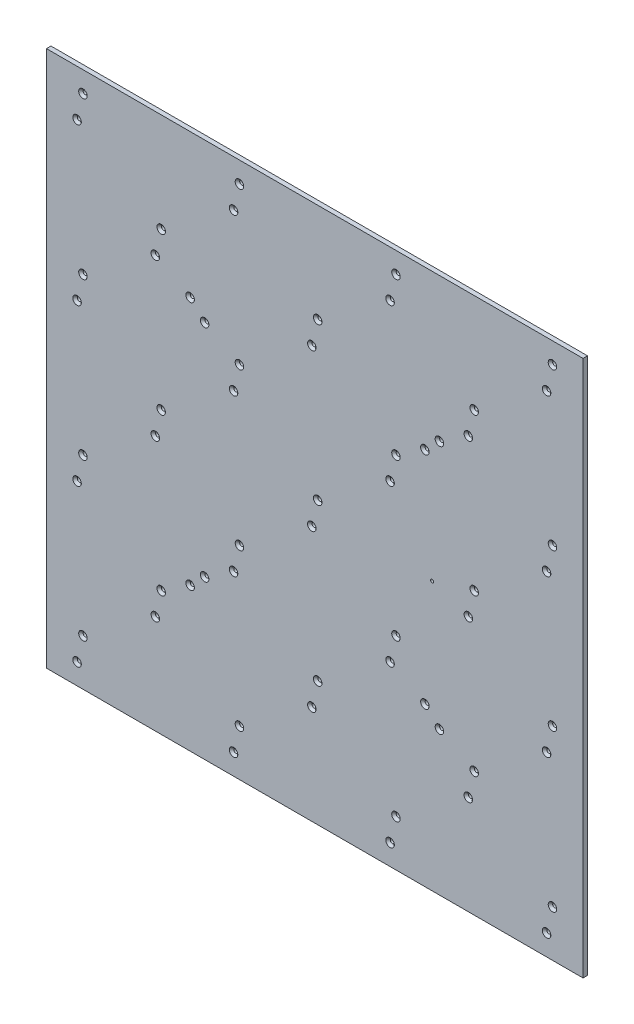
from build123d import *

# Parameters (mm, degrees)
BOSS_EXTRUDE1_START = 3
SKETCH1_W           = 1200
SKETCH1_H           = 1200
BOSS_EXTRUDE1_DEPTH = 10
SKETCH2_R           = 4.5
CUT_EXTRUDE1_DEPTH  = 11
CHAMFER1_SIZE       = 5
CUT_EXTRUDE2_REACH  = 12
SKETCH3_R           = 3.4


with BuildPart() as part:
    # Sketch1 → Boss-Extrude1 (new body)
    with BuildSketch(Plane.XY.offset(BOSS_EXTRUDE1_START)):
        Rectangle(SKETCH1_W, SKETCH1_H)
    extrude(amount=-BOSS_EXTRUDE1_DEPTH)

    # Sketch2 → Cut-Extrude1 (cut, through all)
    with BuildSketch(Plane(origin=(0, 0, -7), x_dir=(-1, 0, 0), z_dir=(0, 0, -1))):
        with Locations((-278.749982464, 278.776929471)):
            Circle(SKETCH2_R)
        with Locations((-246.223070529, 246.250017536)):
            Circle(SKETCH2_R)
        with Locations((246.250017536, 246.223070529)):
            Circle(SKETCH2_R)
        with Locations((278.776929471, 278.749982464)):
            Circle(SKETCH2_R)
        with Locations((246.223070529, -246.250017536)):
            Circle(SKETCH2_R)
        with Locations((278.749982464, -278.776929471)):
            Circle(SKETCH2_R)
        with Locations((-246.250017536, -246.223070529)):
            Circle(SKETCH2_R)
        with Locations((-278.776929471, -278.749982464)):
            Circle(SKETCH2_R)
        with Locations((-531.581664893, 553.513118765)):
            Circle(SKETCH2_R)
        with Locations((-518.429478763, 496.520312201)):
            Circle(SKETCH2_R)
        with Locations((-531.581664893, 203.509404213)):
            Circle(SKETCH2_R)
        with Locations((-518.429478763, 146.516597649)):
            Circle(SKETCH2_R)
        with Locations((-343.427621487, 321.518454925)):
            Circle(SKETCH2_R)
        with Locations((-356.579807617, 378.511261489)):
            Circle(SKETCH2_R)
        with Locations((-181.577950341, 553.513118765)):
            Circle(SKETCH2_R)
        with Locations((-168.425764211, 496.520312201)):
            Circle(SKETCH2_R)
        with Locations((168.425764211, 553.513118765)):
            Circle(SKETCH2_R)
        with Locations((181.577950341, 496.520312201)):
            Circle(SKETCH2_R)
        with Locations((-6.576093065, 378.511261489)):
            Circle(SKETCH2_R)
        with Locations((6.576093065, 321.518454925)):
            Circle(SKETCH2_R)
        with Locations((-181.577950341, 203.509404213)):
            Circle(SKETCH2_R)
        with Locations((-168.425764211, 146.516597649)):
            Circle(SKETCH2_R)
        with Locations((-356.579807617, 28.507546937)):
            Circle(SKETCH2_R)
        with Locations((-343.427621487, -28.485259627)):
            Circle(SKETCH2_R)
        with Locations((-518.429478763, -203.487116903)):
            Circle(SKETCH2_R)
        with Locations((-531.581664893, -146.494310339)):
            Circle(SKETCH2_R)
        with Locations((-531.581664893, -496.498024891)):
            Circle(SKETCH2_R)
        with Locations((-518.429478763, -553.490831454)):
            Circle(SKETCH2_R)
        with Locations((-356.579807617, -321.496167615)):
            Circle(SKETCH2_R)
        with Locations((-343.427621487, -378.488974178)):
            Circle(SKETCH2_R)
        with Locations((-181.577950341, -146.494310339)):
            Circle(SKETCH2_R)
        with Locations((-168.425764211, -203.487116903)):
            Circle(SKETCH2_R)
        with Locations((-6.576093065, 28.507546937)):
            Circle(SKETCH2_R)
        with Locations((6.576093065, -28.485259627)):
            Circle(SKETCH2_R)
        with Locations((168.425764211, 203.509404213)):
            Circle(SKETCH2_R)
        with Locations((181.577950341, 146.516597649)):
            Circle(SKETCH2_R)
        with Locations((343.427621487, 378.511261489)):
            Circle(SKETCH2_R)
        with Locations((356.579807617, 321.518454925)):
            Circle(SKETCH2_R)
        with Locations((518.429478763, 553.513118765)):
            Circle(SKETCH2_R)
        with Locations((531.581664893, 496.520312201)):
            Circle(SKETCH2_R)
        with Locations((-181.577950341, -496.498024891)):
            Circle(SKETCH2_R)
        with Locations((-168.425764211, -553.490831454)):
            Circle(SKETCH2_R)
        with Locations((-6.576093065, -321.496167615)):
            Circle(SKETCH2_R)
        with Locations((6.576093065, -378.488974178)):
            Circle(SKETCH2_R)
        with Locations((168.425764211, -146.494310339)):
            Circle(SKETCH2_R)
        with Locations((181.577950341, -203.487116903)):
            Circle(SKETCH2_R)
        with Locations((343.427621487, 28.507546937)):
            Circle(SKETCH2_R)
        with Locations((356.579807617, -28.485259627)):
            Circle(SKETCH2_R)
        with Locations((518.429478763, 203.509404213)):
            Circle(SKETCH2_R)
        with Locations((531.581664893, 146.516597649)):
            Circle(SKETCH2_R)
        with Locations((168.425764211, -496.498024891)):
            Circle(SKETCH2_R)
        with Locations((181.577950341, -553.490831454)):
            Circle(SKETCH2_R)
        with Locations((343.427621487, -321.496167615)):
            Circle(SKETCH2_R)
        with Locations((356.579807617, -378.488974178)):
            Circle(SKETCH2_R)
        with Locations((531.581664893, -203.487116903)):
            Circle(SKETCH2_R)
        with Locations((518.429478763, -146.494310339)):
            Circle(SKETCH2_R)
        with Locations((518.429478763, -496.498024891)):
            Circle(SKETCH2_R)
        with Locations((531.581664893, -553.490831454)):
            Circle(SKETCH2_R)
    extrude(amount=-CUT_EXTRUDE1_DEPTH, mode=Mode.SUBTRACT)

    # Chamfer1
    chamfer1_edges = [part.edges().sort_by_distance(p)[0] for p in [
        (522.929478763, -553.490831454, 3),
        (361.079807617, -321.496167615, 3),
        (347.927621487, -378.488974178, 3),
        (186.077950341, -146.494310339, 3),
        (172.925764211, -203.487116903, 3),
        (11.076093065, 28.507546937, 3),
        (536.081664893, 553.513118765, 3),
        (283.276929471, -278.749982464, 3),
        (250.750017536, -246.223070529, 3),
        (-274.249982464, -278.776929471, 3),
        (283.249982464, 278.776929471, 3),
        (-241.750017536, 246.223070529, 3),
        (-274.276929471, 278.749982464, 3),
        (-241.723070529, -246.250017536, 3),
        (-163.925764211, 553.513118765, 3),
        (172.925764211, 496.520312201, 3),
        (186.077950341, 553.513118765, 3),
        (361.079807617, 378.511261489, 3),
        (522.929478763, 496.520312201, 3),
        (536.081664893, 203.509404213, 3),
        (522.929478763, 146.516597649, 3),
        (347.927621487, 321.518454925, 3),
        (-352.079807617, -378.488974178, 3),
        (-527.081664893, -203.487116903, 3),
        (-513.929478763, -146.494310339, 3),
        (-513.929478763, -496.498024891, 3),
        (-527.081664893, 146.516597649, 3),
        (-163.925764211, -496.498024891, 3),
        (-177.077950341, -553.490831454, 3),
        (-338.927621487, -321.496167615, 3),
        (-527.081664893, -553.490831454, 3),
        (-352.079807617, 321.518454925, 3),
        (-513.929478763, 553.513118765, 3),
        (-527.081664893, 496.520312201, 3),
        (186.077950341, -496.498024891, 3),
        (-338.927621487, 378.511261489, 3),
        (-177.077950341, 146.516597649, 3),
        (-163.925764211, 203.509404213, 3),
        (-2.076093065, -28.485259627, 3),
        (172.925764211, -553.490831454, 3),
        (11.076093065, -321.496167615, 3),
        (-2.076093065, -378.488974178, 3),
        (-163.925764211, -146.494310339, 3),
        (-177.077950341, -203.487116903, 3),
        (-338.927621487, 28.507546937, 3),
        (-352.079807617, -28.485259627, 3),
        (-513.929478763, 203.509404213, 3),
        (250.723070529, 246.250017536, 3),
        (-177.077950341, 496.520312201, 3),
        (11.076093065, 378.511261489, 3),
        (-2.076093065, 321.518454925, 3),
        (186.077950341, 203.509404213, 3),
        (172.925764211, 146.516597649, 3),
        (361.079807617, 28.507546937, 3),
        (347.927621487, -28.485259627, 3),
        (522.929478763, -203.487116903, 3),
        (536.081664893, -146.494310339, 3),
        (536.081664893, -496.498024891, 3),
    ]]
    chamfer(chamfer1_edges, length=CHAMFER1_SIZE)

    # Sketch3 → Cut-Extrude2 (cut, up to next)
    with BuildSketch(Plane(origin=(0, 0, -7), x_dir=(-1, 0, 0), z_dir=(0, 0, -1)), mode=Mode.PRIVATE) as cut_extrude2_sk1:
        with Locations((-262.5, 0)):
            Circle(SKETCH3_R)
    cut_extrude2_tool1 = extrude(cut_extrude2_sk1.sketch, amount=-CUT_EXTRUDE2_REACH, mode=Mode.PRIVATE) & part.part
    add(cut_extrude2_tool1.solids().sort_by_distance((262.5, 0, -7))[0], mode=Mode.SUBTRACT)


solid = part.part
